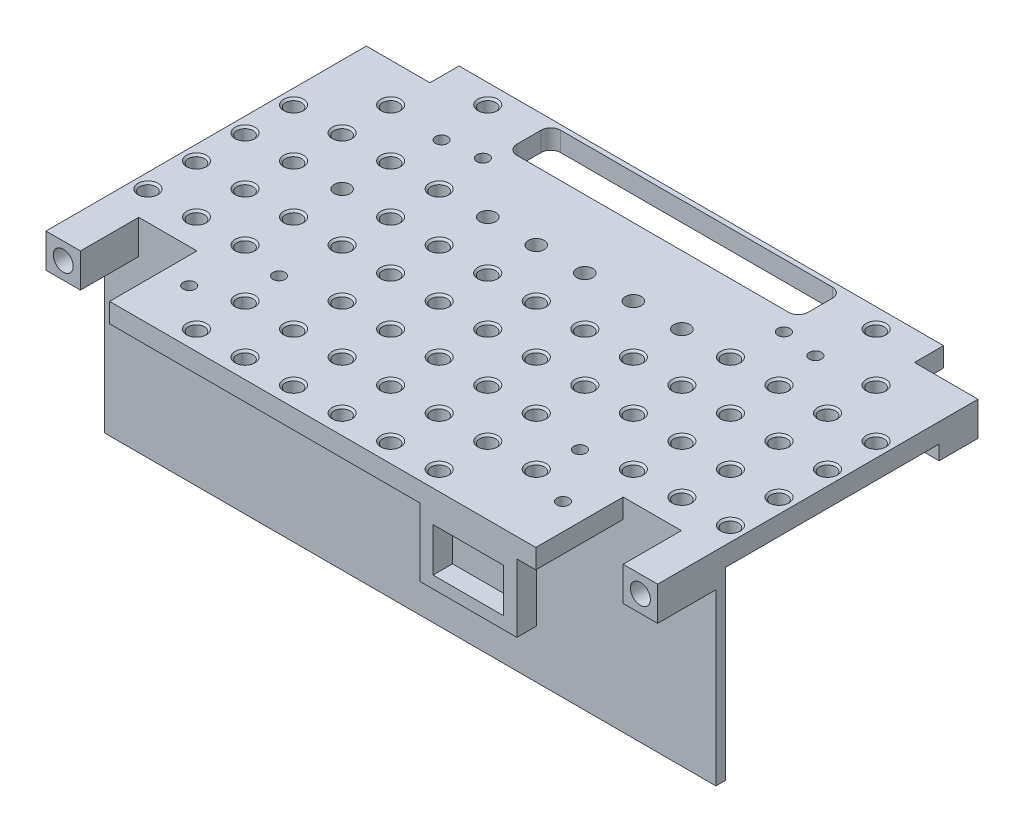
from build123d import *

# Parameters (mm, degrees)
BOSS_EXTRUDE1_DEPTH             = 4
SKETCH3_W                       = 7.1
SKETCH3_H                       = 8
BOSS_EXTRUDE3_DEPTH             = 3
SKETCH4_R                       = 2.05
CUT_EXTRUDE1_DEPTH              = 7
MIRROR2_COPY_1_SKETCH_W         = 7.1
MIRROR2_COPY_1_SKETCH_H         = 8
MIRROR2_COPY_1_DEPTH            = 3
MIRROR2_COPY_2_SKETCH_R         = 2.05
MIRROR2_COPY_2_DEPTH            = 7
SKETCH5_W                       = 60
SKETCH5_H                       = 9
CUT_EXTRUDE2_DEPTH              = 75.953318806
FILLET1_R                       = 2
SKETCH7_W                       = 111.8
SKETCH7_H                       = 1
CUT_EXTRUDE3_DEPTH              = 75.953318806
SKETCH8_W                       = 126
SKETCH8_H                       = 2
BOSS_EXTRUDE4_DEPTH             = 38
SKETCH9_W                       = 12
SKETCH9_H                       = 18
CUT_EXTRUDE4_DEPTH              = 10
SKETCH10_W                      = 7.1
SKETCH10_H                      = 4
BOSS_EXTRUDE5_DEPTH             = 3
SKETCH12_W                      = 1.5
SKETCH12_H                      = 4
BOSS_EXTRUDE6_DEPTH             = 2
SKETCH13_W                      = 40
SKETCH13_H                      = 2
BOSS_EXTRUDE7_DEPTH             = 38
SKETCH14_W                      = 1.5
SKETCH14_H                      = 4
BOSS_EXTRUDE8_DEPTH             = 1
BOSS_EXTRUDE9_REACH             = 85.271
BOSS_EXTRUDE9_DIRECTION_2_REACH = 85.271
SKETCH16_W                      = 20
SKETCH16_H                      = 14
SKETCH16_W_2                    = 14.5
SKETCH16_H_2                    = 9
BOSS_EXTRUDE10_DEPTH            = 4
SKETCH17_W                      = 12
SKETCH17_H                      = 18
CUT_EXTRUDE5_DEPTH              = 84.270643086
SKETCH18_W                      = 6
SKETCH18_H                      = 6
CUT_EXTRUDE6_DEPTH              = 86.170417399
SKETCH22_R                      = 1.25
CUT_EXTRUDE7_DEPTH              = 4
SKETCH23_R                      = 1.65
CUT_EXTRUDE8_DEPTH              = 86.170417399
MIRROR5_COPY_1_SKETCH_R         = 1.65
MIRROR5_COPY_1_DEPTH            = 86.170417399
SKETCH24_R                      = 1.65
CUT_EXTRUDE9_DEPTH              = 86.170417399
CHAMFER1_SIZE                   = 0.4
SKETCH6_R                       = 1.25
CUT_EXTRUDE10_DEPTH             = 4
SKETCH25_W                      = 6
SKETCH25_H                      = 38
CUT_EXTRUDE11_DEPTH             = 10
SKETCH26_W                      = 5.701552738
SKETCH26_H                      = 30.562488548
SKETCH26_W_2                    = 7.53419365
SKETCH26_H_2                    = 28.524331859
CUT_EXTRUDE12_DEPTH             = 85.029756634
CUT_EXTRUDE12_DEPTH_BACK        = 85.029756634


with BuildPart() as part:
    # Sketch1 → Boss-Extrude1 (new body)
    with BuildSketch(Plane(origin=(0, 0, 0), x_dir=(1, 0, 0), z_dir=(0, 1, 0))):
        Polygon((-63, -33), (-55.9, -33), (-55.9, -40), (55.9, -40), (55.9, -33), (63, -33), (63, 33), (55.9, 33), (55.9, 40), (-55.9, 40), (-55.9, 33), (-63, 33), align=None)
    extrude(amount=BOSS_EXTRUDE1_DEPTH)

    # Sketch3 → Boss-Extrude3 (add)
    with BuildSketch(Plane.XZ):
        with Locations((-59.45, -29)):
            Rectangle(SKETCH3_W, SKETCH3_H)
    boss_extrude3 = extrude(amount=BOSS_EXTRUDE3_DEPTH)

    # Sketch4 → Cut-Extrude1 (cut)
    with BuildSketch(Plane(origin=(0, 0, -33), x_dir=(-1, 0, 0), z_dir=(0, 0, -1))):
        with Locations((59.45, 0.5)):
            Circle(SKETCH4_R)
    cut_extrude1 = extrude(amount=-CUT_EXTRUDE1_DEPTH, mode=Mode.SUBTRACT)

    # Mirror1: Boss-Extrude3, Cut-Extrude1 across plane
    add(boss_extrude3.mirror(Plane(origin=(0, 0, 0), x_dir=(0, 0, 1), z_dir=(1, 0, 0))))
    add(cut_extrude1.mirror(Plane(origin=(0, 0, 0), x_dir=(0, 0, 1), z_dir=(1, 0, 0))), mode=Mode.SUBTRACT)

    # Mirror2: Boss-Extrude3, Cut-Extrude1 across plane
    add(boss_extrude3.mirror(Plane.XY))
    add(cut_extrude1.mirror(Plane.XY), mode=Mode.SUBTRACT)

    # Mirror2 copy 1 sketch → Mirror2 copy 1 (add)
    with BuildSketch(Plane(origin=(0, 0, 0), x_dir=(-1, 0, 0), z_dir=(0, -1, 0))):
        with Locations((-59.45, -29)):
            Rectangle(MIRROR2_COPY_1_SKETCH_W, MIRROR2_COPY_1_SKETCH_H)
    extrude(amount=MIRROR2_COPY_1_DEPTH)

    # Mirror2 copy 2 sketch → Mirror2 copy 2 (cut)
    with BuildSketch(Plane.XY.offset(33)):
        with Locations((59.45, 0.5)):
            Circle(MIRROR2_COPY_2_SKETCH_R)
    extrude(amount=-MIRROR2_COPY_2_DEPTH, mode=Mode.SUBTRACT)

    # Sketch5 → Cut-Extrude2 (cut, through all)
    with BuildSketch(Plane(origin=(0, 4, 0), x_dir=(1, 0, 0), z_dir=(0, 1, 0))):
        with Locations((0, 33.5)):
            Rectangle(SKETCH5_W, SKETCH5_H)
    extrude(amount=-CUT_EXTRUDE2_DEPTH, mode=Mode.SUBTRACT)

    # Fillet1
    fillet1_edges = [part.edges().sort_by_distance(p)[0] for p in [
        (-30, 2, -29),
        (-30, 2, -38),
        (30, 2, -38),
        (30, 2, -29),
    ]]
    fillet(fillet1_edges, radius=FILLET1_R)

    # Sketch7 → Cut-Extrude3 (cut, through all)
    with BuildSketch(Plane(origin=(0, 4, 0), x_dir=(1, 0, 0), z_dir=(0, 1, 0))):
        with Locations((0, 39.5)):
            Rectangle(SKETCH7_W, SKETCH7_H)
        with Locations((0, -39.5)):
            Rectangle(SKETCH7_W, SKETCH7_H)
    extrude(amount=-CUT_EXTRUDE3_DEPTH, mode=Mode.SUBTRACT)

    # Sketch8 → Boss-Extrude4 (add)
    with BuildSketch(Plane.XZ):
        with Locations((0, 20)):
            Rectangle(SKETCH8_W, SKETCH8_H)
    extrude(amount=BOSS_EXTRUDE4_DEPTH)

    # Sketch9 → Cut-Extrude4 (cut)
    with BuildSketch(Plane(origin=(0, 4, 0), x_dir=(1, 0, 0), z_dir=(0, 1, 0))):
        with Locations((-49.9, -30)):
            Rectangle(SKETCH9_W, SKETCH9_H)
    extrude(amount=-CUT_EXTRUDE4_DEPTH, mode=Mode.SUBTRACT)

    # Sketch10 → Boss-Extrude5 (add)
    with BuildSketch(Plane.XZ.offset(3)):
        with Locations((-59.45, 23)):
            Rectangle(SKETCH10_W, SKETCH10_H)
        with Locations((59.45, 23)):
            Rectangle(SKETCH10_W, SKETCH10_H)
    extrude(amount=-BOSS_EXTRUDE5_DEPTH)

    # Sketch12 → Boss-Extrude6 (add)
    with BuildSketch(Plane.ZY.offset(56)):
        Polygon((21, -5.8), (21, -16.2), (23.7, -13.5), (23.7, -8.5), align=None)
        with Locations((22.35, -11)):
            Rectangle(SKETCH12_W, SKETCH12_H, mode=Mode.SUBTRACT)
        Polygon((21, -20.8), (21, -31.2), (23.7, -28.5), (23.7, -23.5), align=None)
        with Locations((22.35, -26)):
            Rectangle(SKETCH12_W, SKETCH12_H, mode=Mode.SUBTRACT)
    boss_extrude6 = extrude(amount=-BOSS_EXTRUDE6_DEPTH)

    # Mirror3: Boss-Extrude6 across plane
    add(boss_extrude6.mirror(Plane(origin=(-49.9, 0, 0), x_dir=(0, 0, 1), z_dir=(1, 0, 0))))

    # Sketch13 → Boss-Extrude7 (add)
    with BuildSketch(Plane.XZ):
        with Locations((0, -20.5)):
            Rectangle(SKETCH13_W, SKETCH13_H)
    extrude(amount=BOSS_EXTRUDE7_DEPTH)

    # Sketch14 → Boss-Extrude8 (add, symmetric)
    with BuildSketch(Plane(origin=(0, 0, 0), x_dir=(0, 0, -1), z_dir=(1, 0, 0))):
        Polygon((24.2, -8.5), (21.5, -5.8), (21.5, -16.2), (24.2, -13.5), align=None)
        with Locations((22.85, -11)):
            Rectangle(SKETCH14_W, SKETCH14_H, mode=Mode.SUBTRACT)
        Polygon((24.2, -28.5), (24.2, -23.5), (21.5, -20.8), (21.5, -31.2), align=None)
        with Locations((22.85, -26)):
            Rectangle(SKETCH14_W, SKETCH14_H, mode=Mode.SUBTRACT)
    extrude(amount=BOSS_EXTRUDE8_DEPTH, both=True)

    # Boss-Extrude9: up to this face of the body (flat: up to its plane)
    boss_extrude9_end = Plane(part.part.faces().sort_by_distance((-20, -19, -20.5))[0])
    # Sketch15 → Boss-Extrude9 (add, up to the picked face)
    with BuildSketch(Plane(origin=(0, 0, 0), x_dir=(0, 0, -1), z_dir=(1, 0, 0)), mode=Mode.PRIVATE) as boss_extrude9_sk1:
        Polygon((19.5, 0), (19.5, -5), (16.613248654, 0), align=None)
    boss_extrude9_tool1 = split(extrude(boss_extrude9_sk1.sketch, amount=-BOSS_EXTRUDE9_REACH, mode=Mode.PRIVATE), bisect_by=boss_extrude9_end, keep=Keep.BOTH, mode=Mode.PRIVATE)
    add(boss_extrude9_tool1.solids().sort_by(Axis((0, -1.666667, -18.53775), (-1, 0, 0)))[0])

    # Boss-Extrude9 direction 2: up to this face of the body (flat: up to its plane)
    boss_extrude9_direction_2_end = Plane(part.part.faces().sort_by_distance((20, -19, -20.5))[0])
    # Sketch15 → Boss-Extrude9 direction 2 (add, up to the picked face)
    with BuildSketch(Plane(origin=(0, 0, 0), x_dir=(0, 0, -1), z_dir=(1, 0, 0)), mode=Mode.PRIVATE) as boss_extrude9_direction_2_sk1:
        Polygon((19.5, 0), (19.5, -5), (16.613248654, 0), align=None)
    boss_extrude9_direction_2_tool1 = split(extrude(boss_extrude9_direction_2_sk1.sketch, amount=BOSS_EXTRUDE9_DIRECTION_2_REACH, mode=Mode.PRIVATE), bisect_by=boss_extrude9_direction_2_end, keep=Keep.BOTH, mode=Mode.PRIVATE)
    add(boss_extrude9_direction_2_tool1.solids().sort_by(Axis((0, -1.666667, -18.53775), (1, 0, 0)))[0])

    # Sketch16 → Boss-Extrude10 (add)
    with BuildSketch(Plane.XY.offset(39)):
        with Locations((30, -7)):
            Rectangle(SKETCH16_W, SKETCH16_H)
        with Locations((30, -7)):
            Rectangle(SKETCH16_W_2, SKETCH16_H_2, mode=Mode.SUBTRACT)
    extrude(amount=-BOSS_EXTRUDE10_DEPTH)

    # Sketch17 → Cut-Extrude5 (cut, through all)
    with BuildSketch(Plane.XZ):
        with Locations((49.9, 30)):
            Rectangle(SKETCH17_W, SKETCH17_H)
    extrude(amount=-CUT_EXTRUDE5_DEPTH, mode=Mode.SUBTRACT)

    # Sketch18 → Cut-Extrude6 (cut, through all)
    with BuildSketch(Plane(origin=(0, 4, 0), x_dir=(1, 0, 0), z_dir=(0, 1, 0))):
        with Locations((52.9, 36)):
            Rectangle(SKETCH18_W, SKETCH18_H)
        with Locations((-52.9, 36)):
            Rectangle(SKETCH18_W, SKETCH18_H)
    extrude(amount=-CUT_EXTRUDE6_DEPTH, mode=Mode.SUBTRACT)

    # Sketch22 → Cut-Extrude7 (cut)
    with BuildSketch(Plane(origin=(0, 4, 0), x_dir=(1, 0, 0), z_dir=(0, 1, 0))):
        with Locations(Location((-31, 25, 0), (0, 0, 270))):
            Circle(SKETCH22_R)
        with Locations(Location((31, 25, 0), (0, 0, 270))):
            Circle(SKETCH22_R)
        with Locations(Location((31, -17, 0), (0, 0, 270))):
            Circle(SKETCH22_R)
        with Locations(Location((-31, -17, 0), (0, 0, 270))):
            Circle(SKETCH22_R)
    extrude(amount=-CUT_EXTRUDE7_DEPTH, mode=Mode.SUBTRACT)

    # Sketch23 → Cut-Extrude8 (cut, through all)
    with BuildSketch(Plane(origin=(0, 4, 0), x_dir=(1, 0, 0), z_dir=(0, 1, 0))):
        with Locations(Location((0, -5, 0), (0, 0, 270))):
            Circle(SKETCH23_R)
        with Locations(Location((0, -15, 0), (0, 0, 270))):
            Circle(SKETCH23_R)
        with Locations(Location((-10, -5, 0), (0, 0, 270))):
            Circle(SKETCH23_R)
        with Locations(Location((-20, -5, 0), (0, 0, 270))):
            Circle(SKETCH23_R)
        with Locations(Location((-30, -5, 0), (0, 0, 270))):
            Circle(SKETCH23_R)
        with Locations(Location((-40, -5, 0), (0, 0, 270))):
            Circle(SKETCH23_R)
        with Locations(Location((-50, -5, 0), (0, 0, 270))):
            Circle(SKETCH23_R)
        with Locations(Location((-60, -5, 0), (0, 0, 270))):
            Circle(SKETCH23_R)
        with Locations(Location((-60, -15, 0), (0, 0, 270))):
            Circle(SKETCH23_R)
        with Locations(Location((-50, -15, 0), (0, 0, 270))):
            Circle(SKETCH23_R)
        with Locations(Location((-40, -15, 0), (0, 0, 270))):
            Circle(SKETCH23_R)
        with Locations(Location((-20, -15, 0), (0, 0, 270))):
            Circle(SKETCH23_R)
        with Locations(Location((-10, -15, 0), (0, 0, 270))):
            Circle(SKETCH23_R)
    cut_extrude8 = extrude(amount=-CUT_EXTRUDE8_DEPTH, mode=Mode.SUBTRACT)

    # Mirror4: Cut-Extrude8 across plane
    add(cut_extrude8.mirror(Plane.XY), mode=Mode.SUBTRACT)

    # Mirror5: Cut-Extrude8 across plane
    add(cut_extrude8.mirror(Plane(origin=(0, 0, 0), x_dir=(0, 0, 1), z_dir=(1, 0, 0))), mode=Mode.SUBTRACT)

    # Mirror5 copy 1 sketch → Mirror5 copy 1 (cut, through all)
    with BuildSketch(Plane(origin=(0, 4, 0), x_dir=(-1, 0, 0), z_dir=(0, 1, 0))):
        with Locations(Location((0, -5, 0), (0, 0, 270))):
            Circle(MIRROR5_COPY_1_SKETCH_R)
        with Locations(Location((0, -15, 0), (0, 0, 270))):
            Circle(MIRROR5_COPY_1_SKETCH_R)
        with Locations(Location((-10, -5, 0), (0, 0, 270))):
            Circle(MIRROR5_COPY_1_SKETCH_R)
        with Locations(Location((-20, -5, 0), (0, 0, 270))):
            Circle(MIRROR5_COPY_1_SKETCH_R)
        with Locations(Location((-30, -5, 0), (0, 0, 270))):
            Circle(MIRROR5_COPY_1_SKETCH_R)
        with Locations(Location((-40, -5, 0), (0, 0, 270))):
            Circle(MIRROR5_COPY_1_SKETCH_R)
        with Locations(Location((-50, -5, 0), (0, 0, 270))):
            Circle(MIRROR5_COPY_1_SKETCH_R)
        with Locations(Location((-60, -5, 0), (0, 0, 270))):
            Circle(MIRROR5_COPY_1_SKETCH_R)
        with Locations(Location((-60, -15, 0), (0, 0, 270))):
            Circle(MIRROR5_COPY_1_SKETCH_R)
        with Locations(Location((-50, -15, 0), (0, 0, 270))):
            Circle(MIRROR5_COPY_1_SKETCH_R)
        with Locations(Location((-40, -15, 0), (0, 0, 270))):
            Circle(MIRROR5_COPY_1_SKETCH_R)
        with Locations(Location((-20, -15, 0), (0, 0, 270))):
            Circle(MIRROR5_COPY_1_SKETCH_R)
        with Locations(Location((-10, -15, 0), (0, 0, 270))):
            Circle(MIRROR5_COPY_1_SKETCH_R)
    extrude(amount=-MIRROR5_COPY_1_DEPTH, mode=Mode.SUBTRACT)

    # Sketch24 → Cut-Extrude9 (cut, through all)
    with BuildSketch(Plane(origin=(0, 4, 0), x_dir=(1, 0, 0), z_dir=(0, 1, 0))):
        with Locations(Location((-30, 15, 0), (0, 0, 270))):
            Circle(SKETCH24_R)
        with Locations(Location((30, 15, 0), (0, 0, 270))):
            Circle(SKETCH24_R)
        with Locations(Location((-40, 35, 0), (0, 0, 270))):
            Circle(SKETCH24_R)
        with Locations(Location((-50, 25, 0), (0, 0, 270))):
            Circle(SKETCH24_R)
        with Locations(Location((50, 25, 0), (0, 0, 270))):
            Circle(SKETCH24_R)
        with Locations(Location((40, 35, 0), (0, 0, 270))):
            Circle(SKETCH24_R)
        with Locations(Location((30, -25, 0), (0, 0, 270))):
            Circle(SKETCH24_R)
        with Locations(Location((-30, -25, 0), (0, 0, 270))):
            Circle(SKETCH24_R)
        with Locations(Location((-30, -35, 0), (0, 0, 270))):
            Circle(SKETCH24_R)
        with Locations(Location((-10, -25, 0), (0, 0, 270))):
            Circle(SKETCH24_R)
        with Locations(Location((-10, -35, 0), (0, 0, 270))):
            Circle(SKETCH24_R)
        with Locations(Location((0, -25, 0), (0, 0, 270))):
            Circle(SKETCH24_R)
        with Locations(Location((0, -35, 0), (0, 0, 270))):
            Circle(SKETCH24_R)
        with Locations(Location((10, -25, 0), (0, 0, 270))):
            Circle(SKETCH24_R)
        with Locations(Location((10, -35, 0), (0, 0, 270))):
            Circle(SKETCH24_R)
        with Locations(Location((20, -35, 0), (0, 0, 270))):
            Circle(SKETCH24_R)
        with Locations(Location((20, -25, 0), (0, 0, 270))):
            Circle(SKETCH24_R)
        with Locations(Location((-20, -25, 0), (0, 0, 270))):
            Circle(SKETCH24_R)
        with Locations(Location((-20, -35, 0), (0, 0, 270))):
            Circle(SKETCH24_R)
    extrude(amount=-CUT_EXTRUDE9_DEPTH, mode=Mode.SUBTRACT)

    # Chamfer1
    chamfer1_edges = [part.edges().sort_by_distance(p)[0] for p in [
        (0, 0, 13.35),
        (0, 4, 13.35),
        (-10, 0, 13.35),
        (-10, 4, 13.35),
        (-10, 0, 3.35),
        (-10, 4, 3.35),
        (-20, 0, 3.35),
        (-20, 4, 3.35),
        (-30, 0, 3.35),
        (-30, 4, 3.35),
        (-40, 0, 3.35),
        (-40, 4, 3.35),
        (-50, 0, 3.35),
        (-50, 4, 3.35),
        (-60, 0, 3.35),
        (-60, 4, 3.35),
        (-60, 0, 13.35),
        (-60, 4, 13.35),
        (-50, 0, 13.35),
        (-50, 4, 13.35),
        (-40, 0, 13.35),
        (-40, 4, 13.35),
        (-20, 0, 13.35),
        (-20, 4, 13.35),
        (0, 0, 3.35),
        (0, 4, 3.35),
        (-10, 4, -3.35),
        (-10, 0, -3.35),
        (-20, 4, -3.35),
        (-20, 0, -3.35),
        (-30, 4, -3.35),
        (-30, 0, -3.35),
        (-50, 4, -3.35),
        (-50, 0, -3.35),
        (-60, 4, -3.35),
        (-60, 0, -3.35),
        (-60, 4, -13.35),
        (-60, 0, -13.35),
        (-50, 4, -13.35),
        (-50, 0, -13.35),
        (-40, 4, -13.35),
        (-40, 0, -13.35),
        (0, 4, -3.35),
        (0, 0, -3.35),
        (10, 0, -3.35),
        (10, 4, -3.35),
        (20, 0, -3.35),
        (20, 4, -3.35),
        (30, 0, -3.35),
        (30, 4, -3.35),
        (40, 0, -3.35),
        (40, 4, -3.35),
        (50, 0, -3.35),
        (50, 4, -3.35),
        (60, 0, -3.35),
        (60, 4, -3.35),
        (60, 0, -13.35),
        (60, 4, -13.35),
        (50, 0, -13.35),
        (50, 4, -13.35),
        (40, 0, -13.35),
        (40, 4, -13.35),
        (10, 4, 13.35),
        (10, 0, 13.35),
        (10, 4, 3.35),
        (10, 0, 3.35),
        (20, 4, 3.35),
        (20, 0, 3.35),
        (30, 4, 3.35),
        (30, 0, 3.35),
        (40, 4, 3.35),
        (40, 0, 3.35),
        (50, 4, 3.35),
        (50, 0, 3.35),
        (60, 4, 3.35),
        (60, 0, 3.35),
        (60, 4, 13.35),
        (60, 0, 13.35),
        (50, 4, 13.35),
        (50, 0, 13.35),
        (40, 4, 13.35),
        (40, 0, 13.35),
        (20, 4, 13.35),
        (20, 0, 13.35),
        (20, 0, 23.35),
        (20, 4, 23.35),
        (20, 4, 33.35),
        (10, 0, 33.35),
        (10, 4, 33.35),
        (10, 0, 23.35),
        (10, 4, 23.35),
        (0, 0, 33.35),
        (0, 4, 33.35),
        (0, 0, 23.35),
        (0, 4, 23.35),
        (-10, 0, 33.35),
        (-10, 4, 33.35),
        (-10, 0, 23.35),
        (-10, 4, 23.35),
        (50, 0, -26.65),
        (50, 4, -26.65),
        (-50, 0, -26.65),
        (-50, 4, -26.65),
        (-40, 0, -36.65),
        (-40, 4, -36.65),
        (30, 0, -16.65),
        (30, 4, -16.65),
        (40, 0, -36.65),
        (40, 4, -36.65),
        (30, 0, 23.35),
        (30, 4, 23.35),
        (-30, 0, 23.35),
        (-30, 4, 23.35),
        (-30, 0, 33.35),
        (-30, 4, 33.35),
        (-20, 0, 33.35),
        (-20, 4, 33.35),
        (-20, 0, 23.35),
        (-20, 4, 23.35),
        (-30, 0, -16.65),
        (-30, 4, -16.65),
    ]]
    chamfer(chamfer1_edges, length=CHAMFER1_SIZE)

    # Sketch6 → Cut-Extrude10 (cut)
    with BuildSketch(Plane(origin=(0, 4, 0), x_dir=(1, 0, 0), z_dir=(0, 1, 0))):
        with Locations(Location((-38.5, 24, 0), (0, 0, 270))):
            Circle(SKETCH6_R)
        with Locations(Location((38.5, 24, 0), (0, 0, 270))):
            Circle(SKETCH6_R)
        with Locations(Location((38.5, -28, 0), (0, 0, 270))):
            Circle(SKETCH6_R)
        with Locations(Location((-38.5, -28, 0), (0, 0, 270))):
            Circle(SKETCH6_R)
    extrude(amount=-CUT_EXTRUDE10_DEPTH, mode=Mode.SUBTRACT)

    # Sketch25 → Cut-Extrude11 (cut)
    with BuildSketch(Plane(origin=(0, 0, -21.5), x_dir=(-1, 0, 0), z_dir=(0, 0, -1))):
        with Locations((-17, -19)):
            Rectangle(SKETCH25_W, SKETCH25_H)
        with Locations((17, -19)):
            Rectangle(SKETCH25_W, SKETCH25_H)
    extrude(amount=-CUT_EXTRUDE11_DEPTH, mode=Mode.SUBTRACT)

    # Sketch26 → Cut-Extrude12 (cut, two sides)
    with BuildSketch(Plane.ZY.offset(1)) as cut_extrude12_sk:
        with Locations((-24.350776369, -21.081244274)):
            Rectangle(SKETCH26_W, SKETCH26_H)
        with Locations((24.767096825, -20.06216593)):
            Rectangle(SKETCH26_W_2, SKETCH26_H_2)
    extrude(amount=CUT_EXTRUDE12_DEPTH, mode=Mode.SUBTRACT)
    extrude(cut_extrude12_sk.sketch, amount=-CUT_EXTRUDE12_DEPTH_BACK, mode=Mode.SUBTRACT)


solid = part.part
